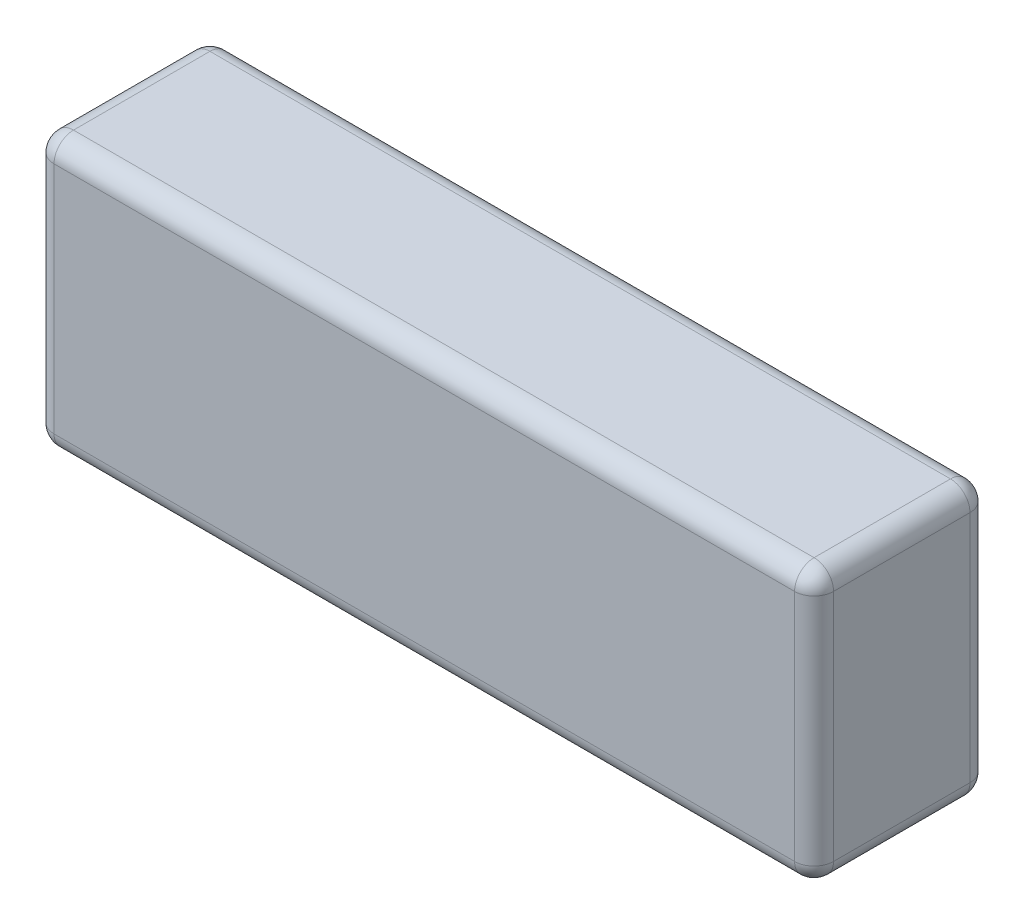
from build123d import *

# Parameters (mm, degrees)
SKETCH1_W      = 10
SKETCH1_H      = 3.5
EXTRUDE1_DEPTH = 1.125
FILLET1_R      = 0.25


with BuildPart() as part:
    # Sketch1 → Extrude1 (new, symmetric)
    with BuildSketch(Plane.XY):
        Rectangle(SKETCH1_W, SKETCH1_H)
    extrude(amount=EXTRUDE1_DEPTH, both=True)

    # Fillet1
    fillet1_edges = [part.edges().sort_by_distance(p)[0] for p in [
        (5, 0, 1.125),
        (0, 1.75, 1.125),
        (-5, 0, 1.125),
        (0, 1.75, -1.125),
        (5, 0, -1.125),
        (0, -1.75, -1.125),
        (-5, 0, -1.125),
        (0, -1.75, 1.125),
        (-5, 1.75, 0),
        (5, 1.75, 0),
        (5, -1.75, 0),
        (-5, -1.75, 0),
    ]]
    fillet(fillet1_edges, radius=FILLET1_R)


solid = part.part
